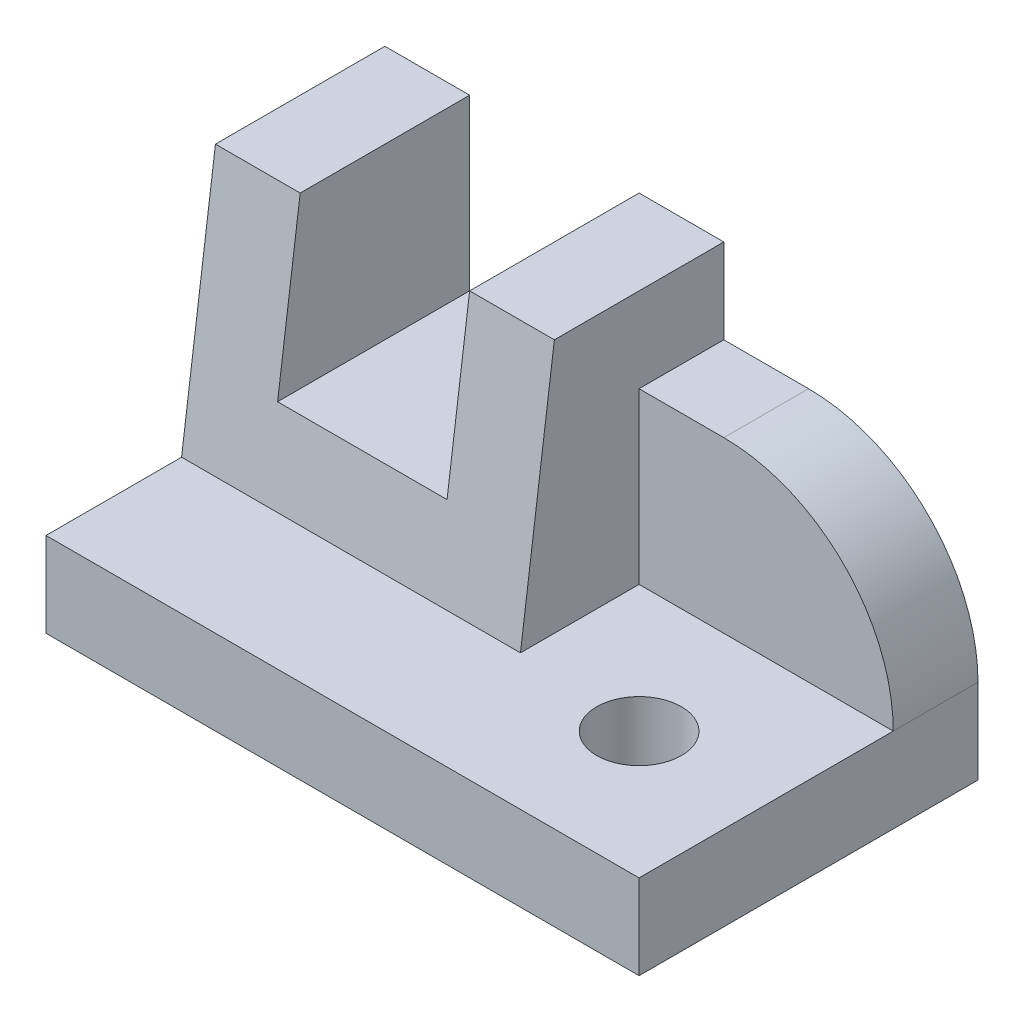
from build123d import *

# Parameters (mm, degrees)
BOSS_EXTRUDE1_DEPTH            = 40
SKETCH2_W                      = 40
SKETCH2_H                      = 30
BOSS_EXTRUDE2_DEPTH            = 20
BOSS_EXTRUDE3_DEPTH            = 30
CUT_EXTRUDE1_DEPTH             = 30
SKETCH5_W                      = 70
SKETCH5_H                      = 40
BOSS_EXTRUDE4_DEPTH            = 10
SKETCH6_W                      = 20
SKETCH6_H                      = 20
CUT_EXTRUDE2_DEPTH             = 41
F_10_0_10_DIAMETER_HOLE1_D     = 10
F_10_0_10_DIAMETER_HOLE1_DEPTH = 40
FILLET1_R                      = 20


with BuildPart() as part:
    # Sketch1 → Boss-Extrude1 (new body)
    with BuildSketch(Plane(origin=(0, 0, 0), x_dir=(0, -1, 0), z_dir=(-1, 0, 0))):
        Polygon((-10, -16), (-40, -20), (-10, -20), align=None)
    extrude(amount=-BOSS_EXTRUDE1_DEPTH)

    # Sketch2 → Boss-Extrude2 (add)
    with BuildSketch(Plane(origin=(0, 0, -20), x_dir=(-1, 0, 0), z_dir=(0, 0, -1))):
        with Locations((-20, 25)):
            Rectangle(SKETCH2_W, SKETCH2_H)
    extrude(amount=BOSS_EXTRUDE2_DEPTH)

    # Sketch3 → Boss-Extrude3 (add)
    with BuildSketch(Plane(origin=(40, 0, 0), x_dir=(0, 0, -1), z_dir=(1, 0, 0))):
        Polygon((40, 10), (0, 10), (20, 40), (40, 40), align=None)
    extrude(amount=BOSS_EXTRUDE3_DEPTH)

    # Sketch4 → Cut-Extrude1 (cut)
    with BuildSketch(Plane(origin=(70, 0, 0), x_dir=(0, 0, -1), z_dir=(1, 0, 0))):
        Polygon((20, 40), (0, 10), (30, 10), (30, 30), (40, 30), (40, 40), align=None)
    extrude(amount=-CUT_EXTRUDE1_DEPTH, mode=Mode.SUBTRACT)

    # Sketch5 → Boss-Extrude4 (add)
    with BuildSketch(Plane.XZ.offset(-10)):
        with Locations((35, -20)):
            Rectangle(SKETCH5_W, SKETCH5_H)
    extrude(amount=BOSS_EXTRUDE4_DEPTH)

    # Sketch6 → Cut-Extrude2 (cut, through all)
    with BuildSketch(Plane(origin=(0, 0, -40), x_dir=(-1, 0, 0), z_dir=(0, 0, -1))):
        with Locations((-20, 30)):
            Rectangle(SKETCH6_W, SKETCH6_H)
    extrude(amount=-CUT_EXTRUDE2_DEPTH, mode=Mode.SUBTRACT)

    # Ø10.0 (10) Diameter Hole1
    with Locations(Plane(origin=(0, 0, 0), x_dir=(-1, 0, 0), z_dir=(0, -1, 0))):
        with Locations((-55, 15)):
            Hole(F_10_0_10_DIAMETER_HOLE1_D / 2, depth=F_10_0_10_DIAMETER_HOLE1_DEPTH)

    # Fillet1
    fillet1_edges = [part.edges().sort_by_distance(p)[0] for p in [
        (70, 30, -35),
    ]]
    fillet(fillet1_edges, radius=FILLET1_R)


solid = part.part
